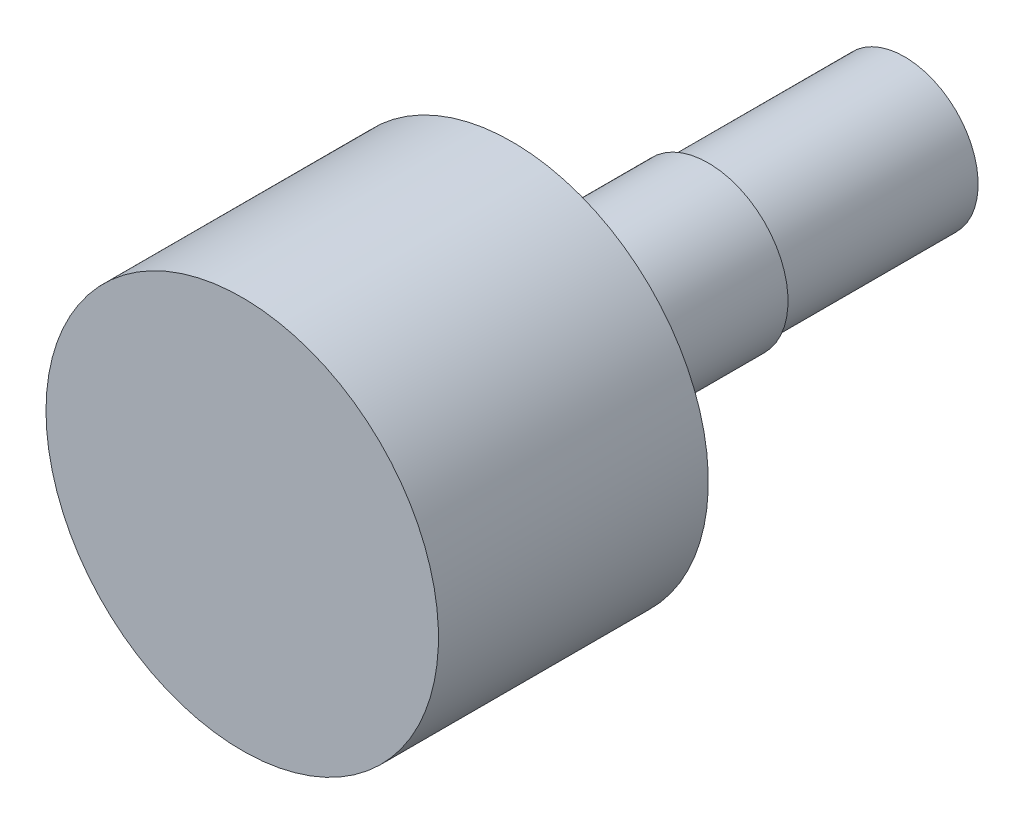
from build123d import *


with BuildPart() as part:
    # Sketch1 → Revolve1 (revolve)
    with BuildSketch(Plane(origin=(0, 0, 0), x_dir=(0, 0, -1), z_dir=(1, 0, 0))):
        Polygon((0, 0), (0, 8), (11, 8), (11, 3.25), (19, 3.25), (19, 3), (27, 3), (27, 0), align=None)
    revolve(axis=Axis((0, 0, 0), (0, 0, 1)))


solid = part.part
